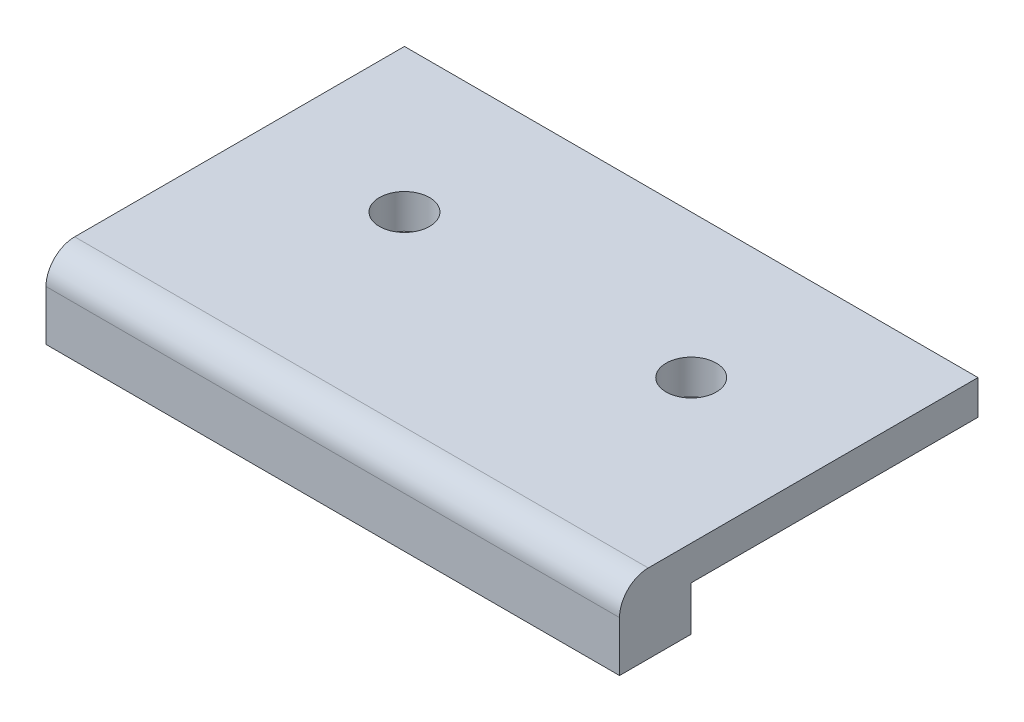
from build123d import *

# Parameters (mm, degrees)
SKETCH1_W           = 40
SKETCH1_H           = 20
SKETCH1_R           = 1.75
BOSS_EXTRUDE1_DEPTH = 2.4
SKETCH2_W           = 40
SKETCH2_H           = 5
BOSS_EXTRUDE2_DEPTH = 5.5
FILLET1_R           = 2


with BuildPart() as part:
    # Sketch1 → Boss-Extrude1 (new body)
    with BuildSketch(Plane(origin=(0, 0, 0), x_dir=(1, 0, 0), z_dir=(0, 1, 0))):
        with Locations((20, 10)):
            Rectangle(SKETCH1_W, SKETCH1_H)
        with Locations((10, 10)):
            Circle(SKETCH1_R, mode=Mode.SUBTRACT)
        with Locations((30, 10)):
            Circle(SKETCH1_R, mode=Mode.SUBTRACT)
    extrude(amount=BOSS_EXTRUDE1_DEPTH)

    # Sketch2 → Boss-Extrude2 (add)
    with BuildSketch(Plane(origin=(0, 2.4, 0), x_dir=(1, 0, 0), z_dir=(0, 1, 0))):
        with Locations((20, -2.5)):
            Rectangle(SKETCH2_W, SKETCH2_H)
    extrude(amount=-BOSS_EXTRUDE2_DEPTH)

    # Fillet1
    fillet1_edges = [part.edges().sort_by_distance(p)[0] for p in [
        (20, 2.4, 5),
    ]]
    fillet(fillet1_edges, radius=FILLET1_R)


solid = part.part
